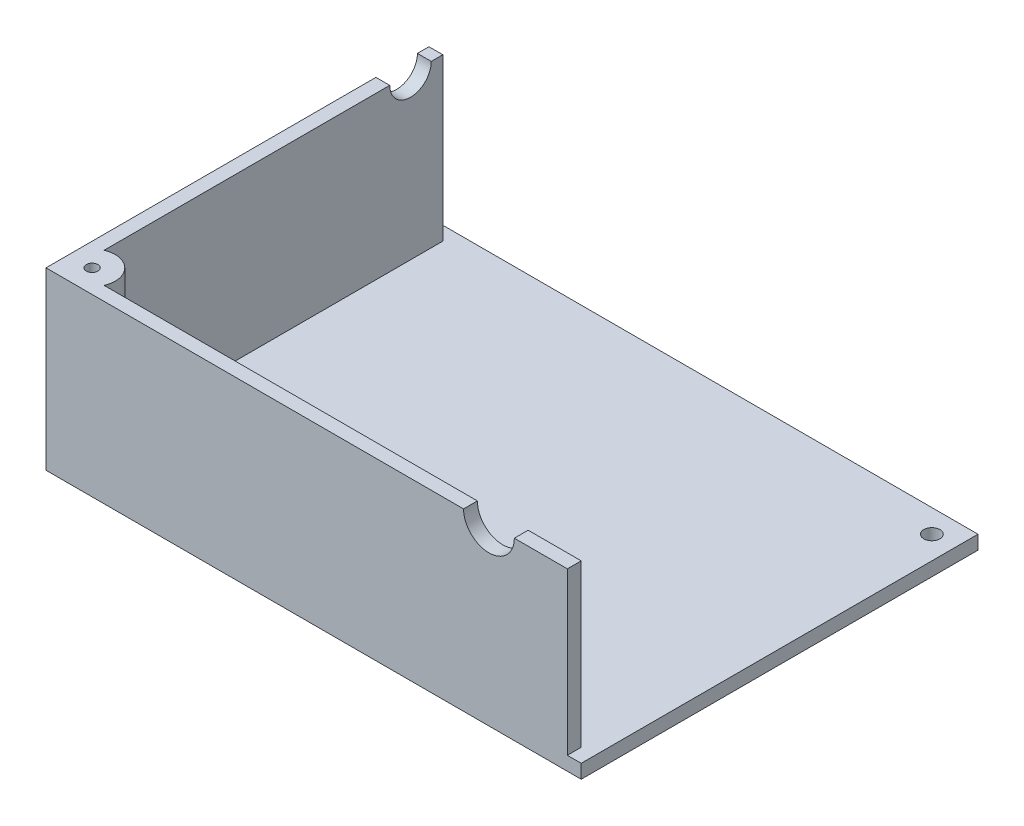
from build123d import *

# Parameters (mm, degrees)
SKETCH1_W           = 116
SKETCH1_H           = 86
BOSS_EXTRUDE1_DEPTH = 3
SKETCH2_W           = 113
SKETCH2_H           = 3
BOSS_EXTRUDE2_DEPTH = 35
SKETCH3_W           = 3
SKETCH3_H           = 80
BOSS_EXTRUDE3_DEPTH = 35
SKETCH4_R           = 1.75
CUT_EXTRUDE1_DEPTH  = 35
SKETCH5_R           = 5
SKETCH5_R_2         = 1.25
BOSS_EXTRUDE4_DEPTH = 10
SKETCH6_R           = 5.5
CUT_EXTRUDE2_DEPTH  = 10
SKETCH7_R           = 4.5
CUT_EXTRUDE3_DEPTH  = 10


with BuildPart() as part:
    # Sketch1 → Boss-Extrude1 (new body)
    with BuildSketch(Plane(origin=(0, 0, 0), x_dir=(1, 0, 0), z_dir=(0, 1, 0))):
        with Locations((58, 43)):
            Rectangle(SKETCH1_W, SKETCH1_H)
    extrude(amount=BOSS_EXTRUDE1_DEPTH)

    # Sketch2 → Boss-Extrude2 (add)
    with BuildSketch(Plane(origin=(0, 3, 0), x_dir=(1, 0, 0), z_dir=(0, 1, 0))):
        with Locations((56.5, 1.5)):
            Rectangle(SKETCH2_W, SKETCH2_H)
    extrude(amount=BOSS_EXTRUDE2_DEPTH)

    # Sketch3 → Boss-Extrude3 (add)
    with BuildSketch(Plane(origin=(0, 3, 0), x_dir=(1, 0, 0), z_dir=(0, 1, 0))):
        with Locations((1.5, 43)):
            Rectangle(SKETCH3_W, SKETCH3_H)
    extrude(amount=BOSS_EXTRUDE3_DEPTH)

    # Sketch4 → Cut-Extrude1 (cut)
    with BuildSketch(Plane.XZ):
        with Locations((111, -81)):
            Circle(SKETCH4_R)
    extrude(amount=-CUT_EXTRUDE1_DEPTH, mode=Mode.SUBTRACT)

    # Sketch5 → Boss-Extrude4 (add)
    with BuildSketch(Plane(origin=(0, 38, 0), x_dir=(1, 0, 0), z_dir=(0, 1, 0))):
        with Locations((5, 5)):
            Circle(SKETCH5_R)
        with Locations((5, 5)):
            Circle(SKETCH5_R_2, mode=Mode.SUBTRACT)
    extrude(amount=-BOSS_EXTRUDE4_DEPTH)

    # Sketch6 → Cut-Extrude2 (cut)
    with BuildSketch(Plane.XY):
        with Locations((96, 38)):
            Circle(SKETCH6_R)
    extrude(amount=-CUT_EXTRUDE2_DEPTH, mode=Mode.SUBTRACT)

    # Sketch7 → Cut-Extrude3 (cut)
    with BuildSketch(Plane.ZY):
        with Locations((-76, 38)):
            Circle(SKETCH7_R)
    extrude(amount=-CUT_EXTRUDE3_DEPTH, mode=Mode.SUBTRACT)


solid = part.part
